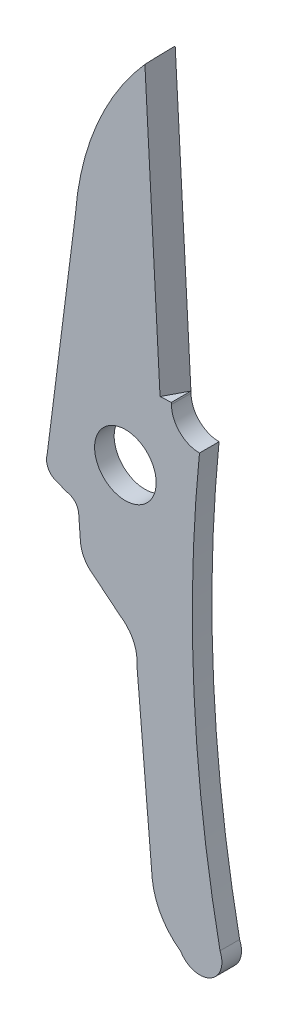
from build123d import *

# Parameters (mm, degrees)
SKETCH1_R           = 1.397
BOSS_EXTRUDE1_DEPTH = 0.4445
CUT_EXTRUDE4_DEPTH  = 16.51


with BuildPart() as part:
    # Sketch1 → Boss-Extrude1 (new body, symmetric)
    with BuildSketch(Plane.XY):
        with BuildLine():
            Line((8.875350221, 21.396721542), (9.593451212, 8.117540032))
            ThreePointArc((9.593451212, 8.117540032), (9.965793887, 7.218625297), (10.864708622, 6.846282623))
            ThreePointArc((10.864708622, 6.846282623), (10.617082025, -2.734099475), (11.797183673, -12.24474615))
            ThreePointArc((11.797183673, -12.24474615), (11.337518417, -13.544150853), (10.014382728, -13.158072262))
            ThreePointArc((10.014382728, -13.158072262), (9.129349257, -12.193661404), (8.721848155, -10.949750073))
            Line((8.721848155, -10.949750073), (8.027558013, -2.912032354))
            ThreePointArc((8.027558013, -2.912032354), (7.861230576, -2.018292431), (7.257903508, -1.338268672))
            Line((7.257903508, -1.338268672), (6.065443849, -0.36416915))
            ThreePointArc((6.065443849, -0.36416915), (5.635017487, 0.104064915), (5.461813548, 0.716037454))
            Line((5.461813548, 0.716037454), (5.388890296, 1.679566547))
            ThreePointArc((5.388890296, 1.679566547), (5.241652075, 2.085780608), (4.868329056, 2.303309644))
            Line((4.868329056, 2.303309644), (4.419812025, 2.47021505))
            ThreePointArc((4.419812025, 2.47021505), (4.011456456, 2.79440081), (3.951939413, 3.312385751))
            Line((3.951939413, 3.312385751), (5.241652075, 13.449796826))
            ThreePointArc((5.241652075, 13.449796826), (6.353290153, 17.745713967), (8.875350221, 21.396721542))
        make_face()
        with Locations((7.503950751, 4.690757252)):
            Circle(SKETCH1_R, mode=Mode.SUBTRACT)
    extrude(amount=BOSS_EXTRUDE1_DEPTH, both=True)

    # Sketch2 → Cut-Extrude4 (cut)
    with BuildSketch(Plane(origin=(-1.305559533, 24.142512274, 0), x_dir=(0.998541027, 0.053998306, 0), z_dir=(-0.053998306, 0.998541027, 0))):
        Polygon((10.017788036, 0.4445), (10.017788036, -0.4445), (9.504523646, -0.4445), align=None)
    extrude(amount=-CUT_EXTRUDE4_DEPTH, mode=Mode.SUBTRACT)


solid = part.part
